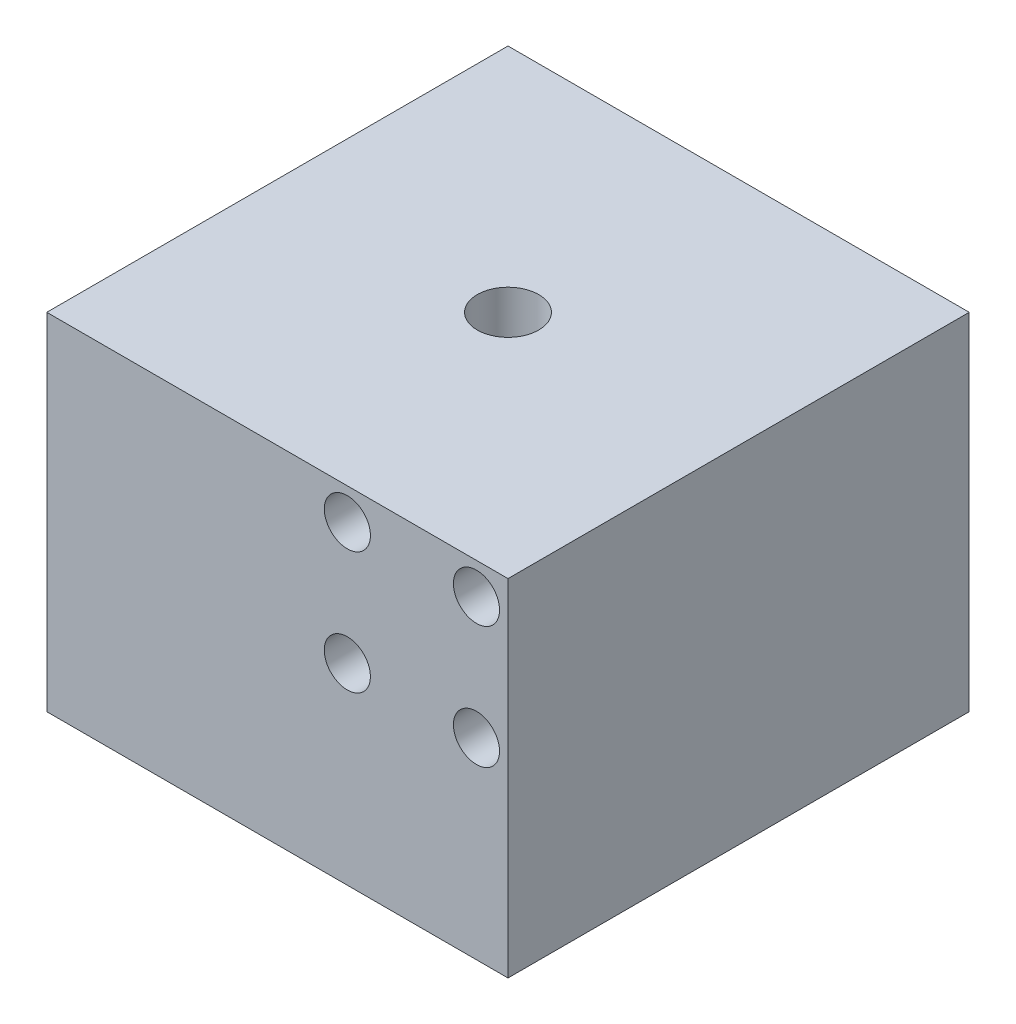
from build123d import *

# Parameters (mm, degrees)
SKETCH_1_W               = 60
SKETCH_1_H               = 45
EXTRUDE_1_DEPTH          = 60
CUT_EXTRUDE_1_DEPTH      = 81.777472107
CUT_EXTRUDE_1_DEPTH_BACK = 81.777472107
SKETCH_3_R               = 4
CUT_EXTRUDE_2_DEPTH      = 71.75485849
CUT_EXTRUDE_2_DEPTH_BACK = 71.75485849
SKETCH_4_R               = 3
CUT_EXTRUDE_8_DEPTH      = 7.2
CUT_EXTRUDE_9_REACH      = 81.547
SKETCH_6_W               = 14.4
SKETCH_6_H               = 6.7


with BuildPart() as part:
    # 스케치1 → 보스-돌출1 (new body)
    with BuildSketch(Plane.XY):
        Rectangle(SKETCH_1_W, SKETCH_1_H)
    extrude(amount=EXTRUDE_1_DEPTH)

    # 스케치2 → 컷-회전1 (revolve, cut)
    with BuildSketch(Plane(origin=(0, 0, 30), x_dir=(-1, 0, 0), z_dir=(0, 0, -1))):
        Polygon((0, 17.5), (0, -22.5), (-27, -22.5), align=None)
    revolve(axis=Axis((0, 17.5, 30), (0, -1, 0)), mode=Mode.SUBTRACT)

    # 스케치3 → 컷-돌출1 (cut, two sides: drawn at the far end of the back side and taken through both)
    with BuildSketch(Plane(origin=(0, 22.5, 0), x_dir=(1, 0, 0), z_dir=(0, 1, 0)).offset(-CUT_EXTRUDE_1_DEPTH_BACK)):
        with Locations((0, -30)):
            Circle(SKETCH_3_R)
    extrude(amount=CUT_EXTRUDE_1_DEPTH + CUT_EXTRUDE_1_DEPTH_BACK, mode=Mode.SUBTRACT)

    # 스케치4 → 컷-돌출2 (cut, two sides: drawn at the far end of the back side and taken through both)
    with BuildSketch(Plane(origin=(0, 0, 0), x_dir=(-1, 0, 0), z_dir=(0, 0, -1)).offset(-CUT_EXTRUDE_2_DEPTH_BACK)):
        with Locations((-25.9, 18.4)):
            Circle(SKETCH_4_R)
        with Locations((-25.9, 2.5)):
            Circle(SKETCH_4_R)
        with Locations((-9.1, 18.4)):
            Circle(SKETCH_4_R)
        with Locations((-9.1, 2.5)):
            Circle(SKETCH_4_R)
    extrude(amount=CUT_EXTRUDE_2_DEPTH + CUT_EXTRUDE_2_DEPTH_BACK, mode=Mode.SUBTRACT)

    # 스케치5 → 컷-돌출8 (cut, symmetric)
    with BuildSketch(Plane(origin=(0, 0, 30), x_dir=(-1, 0, 0), z_dir=(0, 0, -1))):
        Polygon((15.370551943, 3.576426178), (27.958691181, -15.072668989), (30, -13.694785536), (30, 22.5), (11.174505531, 9.792791233), align=None)
    extrude(amount=CUT_EXTRUDE_8_DEPTH, both=True, mode=Mode.SUBTRACT)

    # 스케치6 → 컷-돌출9 (cut, up to next)
    with BuildSketch(Plane(origin=(-12.217871783, 8.247063453, 0), x_dir=(0, 0, 1), z_dir=(-0.8288486740756481, 0.5594728550010628, 0)), mode=Mode.PRIVATE) as cut_extrude_9_sk1:
        with Locations((30, -1.485090483)):
            Rectangle(SKETCH_6_W, SKETCH_6_H)
    cut_extrude_9_tool1 = extrude(cut_extrude_9_sk1.sketch, amount=-CUT_EXTRUDE_9_REACH, mode=Mode.PRIVATE) & part.part
    add(cut_extrude_9_tool1.solids().sort_by_distance((-13.04874, 7.016148, 30))[0], mode=Mode.SUBTRACT)


solid = part.part
